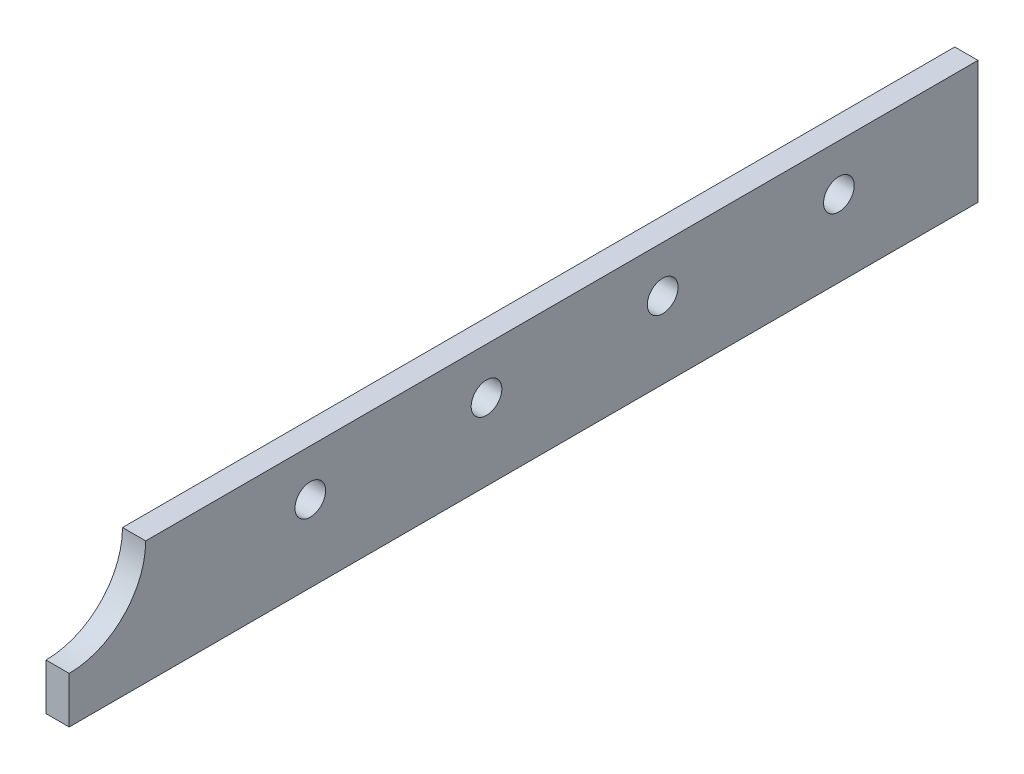
from build123d import *

# Parameters (mm, degrees)
BOSS_EXTRUDE1_DEPTH = 3.175
SKETCH3_R           = 2.1
CUT_EXTRUDE1_DEPTH  = 4.175


with BuildPart() as part:
    # Sketch1 → Boss-Extrude1 (new body)
    with BuildSketch(Plane(origin=(0, 0, 0), x_dir=(0, 0, -1), z_dir=(1, 0, 0))):
        with BuildLine():
            Line((-62.23, -8.4201), (62.23, -8.4201))
            Line((62.23, -8.4201), (62.23, 8.4201))
            Line((62.23, 8.4201), (-51.7525, 8.4201))
            ThreePointArc((-51.7525, 8.4201), (-54.8212887, 1.0113887), (-62.23, -2.0574))
            Line((-62.23, -2.0574), (-62.23, -8.4201))
        make_face()
    extrude(amount=BOSS_EXTRUDE1_DEPTH)

    # Sketch3 → Cut-Extrude1 (cut, through all)
    with BuildSketch(Plane.ZY):
        with Locations((-43.18, 2.0701)):
            Circle(SKETCH3_R)
        with Locations((-19.05, 2.0701)):
            Circle(SKETCH3_R)
        with Locations((5.08, 2.0701)):
            Circle(SKETCH3_R)
        with Locations((29.21, 2.0701)):
            Circle(SKETCH3_R)
    extrude(amount=-CUT_EXTRUDE1_DEPTH, mode=Mode.SUBTRACT)


solid = part.part
